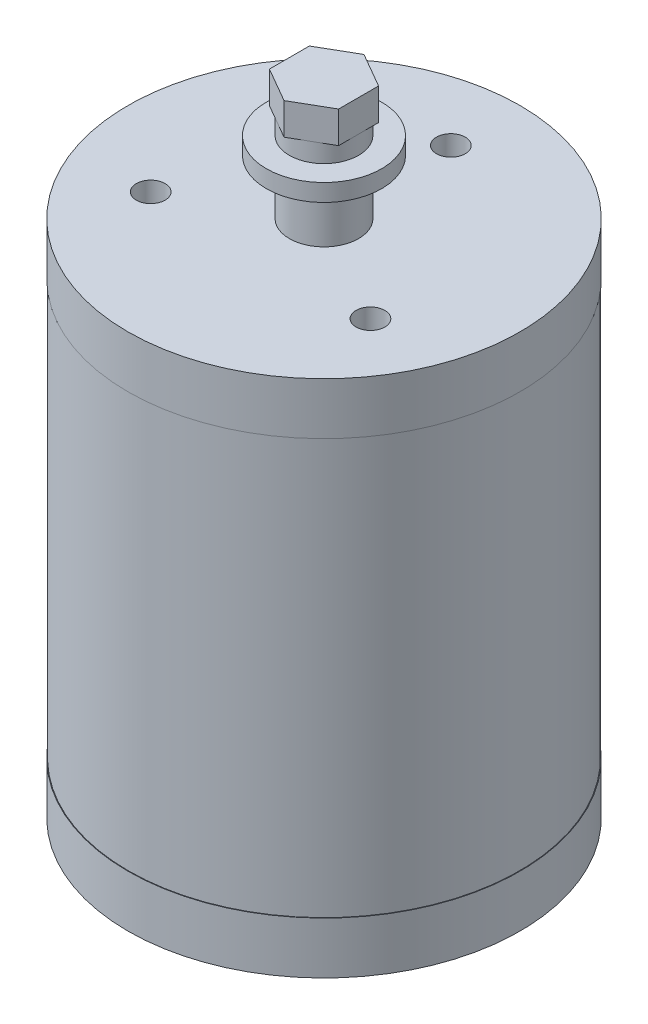
from build123d import *

# Parameters (mm, degrees)
SKETCH1_R                  = 34
MAINHOUSING_DEPTH          = 90
SKETCH2_R                  = 15
REARPART_DEPTH             = 10
SKETCH3_R                  = 6
SHAFT_DEPTH                = 9.5
SKETCH4_R                  = 10
GEAR_DEPTH                 = 3
HEXBOLT_DEPTH              = 8.7
SKETCH6_R                  = 10
SKETCH6_R_2                = 6
HEXBOLTCUTOUT_DEPTH        = 3.2
TOP_BOTTOMSEPERATION_START = 9
SKETCH7_R                  = 34
SKETCH7_R_2                = 33.9
TOP_BOTTOMSEPERATION_DEPTH = 72
SKETCH8_R                  = 2.5
SCREWHOLE_DEPTH            = 12.4
SCREWHOLEPATTERN_COUNT     = 3


with BuildPart() as part:
    # Sketch1 → MainHousing (new body)
    with BuildSketch(Plane(origin=(0, 0, 0), x_dir=(1, 0, 0), z_dir=(0, 1, 0))):
        Circle(SKETCH1_R)
    extrude(amount=MAINHOUSING_DEPTH)

    # Sketch2 → RearPart (add)
    with BuildSketch(Plane.XZ):
        Circle(SKETCH2_R)
    extrude(amount=REARPART_DEPTH)

    # Sketch3 → Shaft (add)
    with BuildSketch(Plane(origin=(0, 90, 0), x_dir=(1, 0, 0), z_dir=(0, 1, 0))):
        Circle(SKETCH3_R)
    extrude(amount=SHAFT_DEPTH)

    # Sketch4 → Gear (add)
    with BuildSketch(Plane(origin=(0, 99.5, 0), x_dir=(1, 0, 0), z_dir=(0, 1, 0))):
        Circle(SKETCH4_R)
    extrude(amount=GEAR_DEPTH)

    # Sketch5 → HexBolt (add)
    with BuildSketch(Plane(origin=(0, 102.5, 0), x_dir=(1, 0, 0), z_dir=(0, 1, 0))):
        Polygon((0, 6.92820323), (-6, 3.464101615), (-6, -3.464101615), (0, -6.92820323), (6, -3.464101615), (6, 3.464101615), align=None)
    extrude(amount=HEXBOLT_DEPTH)

    # Sketch6 → HexBoltCutout (cut)
    with BuildSketch(Plane(origin=(0, 102.5, 0), x_dir=(1, 0, 0), z_dir=(0, 1, 0))):
        Circle(SKETCH6_R)
        Circle(SKETCH6_R_2, mode=Mode.SUBTRACT)
    extrude(amount=HEXBOLTCUTOUT_DEPTH, mode=Mode.SUBTRACT)

    # Sketch7 → Top/BottomSeperation (cut)
    with BuildSketch(Plane(origin=(0, 0, 0), x_dir=(1, 0, 0), z_dir=(0, 1, 0)).offset(TOP_BOTTOMSEPERATION_START)):
        Circle(SKETCH7_R)
        Circle(SKETCH7_R_2, mode=Mode.SUBTRACT)
    extrude(amount=TOP_BOTTOMSEPERATION_DEPTH, mode=Mode.SUBTRACT)

    # Sketch8 → ScrewHole (cut)
    with BuildSketch(Plane(origin=(0, 90, 0), x_dir=(1, 0, 0), z_dir=(0, 1, 0))):
        with Locations((0, 22)):
            Circle(SKETCH8_R)
    screwhole = extrude(amount=-SCREWHOLE_DEPTH, mode=Mode.SUBTRACT)

    # ScrewHolePattern: ScrewHole ×3 about axis
    screwholepattern_axis = Axis((0, 0, 0), (0, 1, 0))
    for i in range(1, SCREWHOLEPATTERN_COUNT):
        add(screwhole.rotate(screwholepattern_axis, i * 360 / SCREWHOLEPATTERN_COUNT), mode=Mode.SUBTRACT)


solid = part.part
